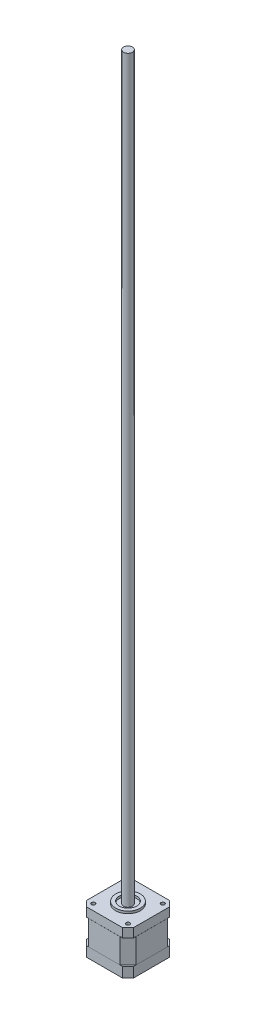
from build123d import *

# Parameters (mm, degrees)
ESBO_O1_W                                            = 42
ESBO_O1_H                                            = 42
RESSALTO_EXTRUS_O1_DEPTH                             = 9
RESSALTO_EXTRUS_O2_DEPTH                             = 22
ESBO_O3_W                                            = 42
ESBO_O3_H                                            = 42
RESSALTO_EXTRUS_O3_DEPTH                             = 8
ESBO_O4_R                                            = 11
ESBO_O4_R_2                                          = 7.8
RESSALTO_EXTRUS_O4_DEPTH                             = 2
BROCA_DE_ROSQUEAR_PARA_TARRAXA_DE_M41_D              = 3.3
BROCA_DE_ROSQUEAR_PARA_TARRAXA_DE_M41_DEPTH          = 20
BROCA_DE_ROSQUEAR_PARA_TARRAXA_DE_M41_TIP            = 0.991420021
CHANFRO1_SIZE                                        = 5
REBAIXO_PARA_PARAFUSO_ALLEN_SEXTAVADO_DE_D           = 3.4
REBAIXO_PARA_PARAFUSO_ALLEN_SEXTAVADO_DE_DEPTH       = 10
REBAIXO_PARA_PARAFUSO_ALLEN_SEXTAVADO_DE_CBORE_D     = 6.5
REBAIXO_PARA_PARAFUSO_ALLEN_SEXTAVADO_DE_CBORE_DEPTH = 3.4
REBAIXO_PARA_PARAFUSO_ALLEN_SEXTAVADO_DE_TIP         = 1.021463052
ESBO_O10_R                                           = 4
BOSS_EXTRUDE1_DEPTH                                  = 660.4


with BuildPart() as part:
    # Esboço1 → Ressalto-extrusão1 (new body)
    with BuildSketch(Plane(origin=(0, 0, 0), x_dir=(1, 0, 0), z_dir=(0, 1, 0))):
        Rectangle(ESBO_O1_W, ESBO_O1_H)
    extrude(amount=RESSALTO_EXTRUS_O1_DEPTH)

    # Esboço2 → Ressalto-extrusão2 (add)
    with BuildSketch(Plane(origin=(0, 9, 0), x_dir=(1, 0, 0), z_dir=(0, 1, 0))):
        Polygon((14, 21.05), (21.05, 14), (21.05, -14), (14, -21.05), (-14, -21.05), (-21.05, -14), (-21.05, 14), (-14, 21.05), align=None)
    extrude(amount=RESSALTO_EXTRUS_O2_DEPTH)

    # Esboço3 → Ressalto-extrusão3 (add)
    with BuildSketch(Plane(origin=(0, 31, 0), x_dir=(1, 0, 0), z_dir=(0, 1, 0))):
        Rectangle(ESBO_O3_W, ESBO_O3_H)
    extrude(amount=RESSALTO_EXTRUS_O3_DEPTH)

    # Esboço4 → Ressalto-extrusão4 (add)
    with BuildSketch(Plane(origin=(0, 39, 0), x_dir=(1, 0, 0), z_dir=(0, 1, 0))):
        Circle(ESBO_O4_R)
        Circle(ESBO_O4_R_2, mode=Mode.SUBTRACT)
    extrude(amount=RESSALTO_EXTRUS_O4_DEPTH)

    # Broca de rosquear para tarraxa de M41
    with Locations(Plane(origin=(0, 39, 0), x_dir=(1, 0, 0), z_dir=(0, 1, 0))):
        with Locations((-15.5, -15.5), (-15.5, 15.5), (15.55, 15.5), (15.5, -15.5)):
            Hole(BROCA_DE_ROSQUEAR_PARA_TARRAXA_DE_M41_D / 2, depth=BROCA_DE_ROSQUEAR_PARA_TARRAXA_DE_M41_DEPTH)
            with Locations((0, 0, -(BROCA_DE_ROSQUEAR_PARA_TARRAXA_DE_M41_DEPTH + BROCA_DE_ROSQUEAR_PARA_TARRAXA_DE_M41_TIP / 2))):  # 118° drill point
                Cone(0, BROCA_DE_ROSQUEAR_PARA_TARRAXA_DE_M41_D / 2, BROCA_DE_ROSQUEAR_PARA_TARRAXA_DE_M41_TIP, mode=Mode.SUBTRACT)

    # Chanfro1
    chanfro1_edges = [part.edges().sort_by_distance(p)[0] for p in [
        (-21, 35, -21),
        (-21, 35, 21),
        (21, 35, 21),
        (21, 35, -21),
        (21, 4.5, -21),
        (-21, 4.5, -21),
        (-21, 4.5, 21),
        (21, 4.5, 21),
    ]]
    chamfer(chanfro1_edges, length=CHANFRO1_SIZE)

    # Rebaixo para parafuso Allen sextavado de M31
    with Locations(Plane(origin=(0, 0, 0), x_dir=(-1, 0, 0), z_dir=(0, -1, 0))):
        with Locations((-15.5, 15.5), (15.5, 15.5), (15.5, -15.5), (-15.5, -15.5)):
            CounterBoreHole(REBAIXO_PARA_PARAFUSO_ALLEN_SEXTAVADO_DE_D / 2, REBAIXO_PARA_PARAFUSO_ALLEN_SEXTAVADO_DE_CBORE_D / 2, REBAIXO_PARA_PARAFUSO_ALLEN_SEXTAVADO_DE_CBORE_DEPTH, depth=REBAIXO_PARA_PARAFUSO_ALLEN_SEXTAVADO_DE_DEPTH)
            with Locations((0, 0, -(REBAIXO_PARA_PARAFUSO_ALLEN_SEXTAVADO_DE_DEPTH + REBAIXO_PARA_PARAFUSO_ALLEN_SEXTAVADO_DE_TIP / 2))):  # 118° drill point
                Cone(0, REBAIXO_PARA_PARAFUSO_ALLEN_SEXTAVADO_DE_D / 2, REBAIXO_PARA_PARAFUSO_ALLEN_SEXTAVADO_DE_TIP, mode=Mode.SUBTRACT)

    # Esboço10 → Boss-Extrude1 (add)
    with BuildSketch(Plane(origin=(0, 39, 0), x_dir=(1, 0, 0), z_dir=(0, 1, 0))):
        Circle(ESBO_O10_R)
    extrude(amount=BOSS_EXTRUDE1_DEPTH)


solid = part.part
